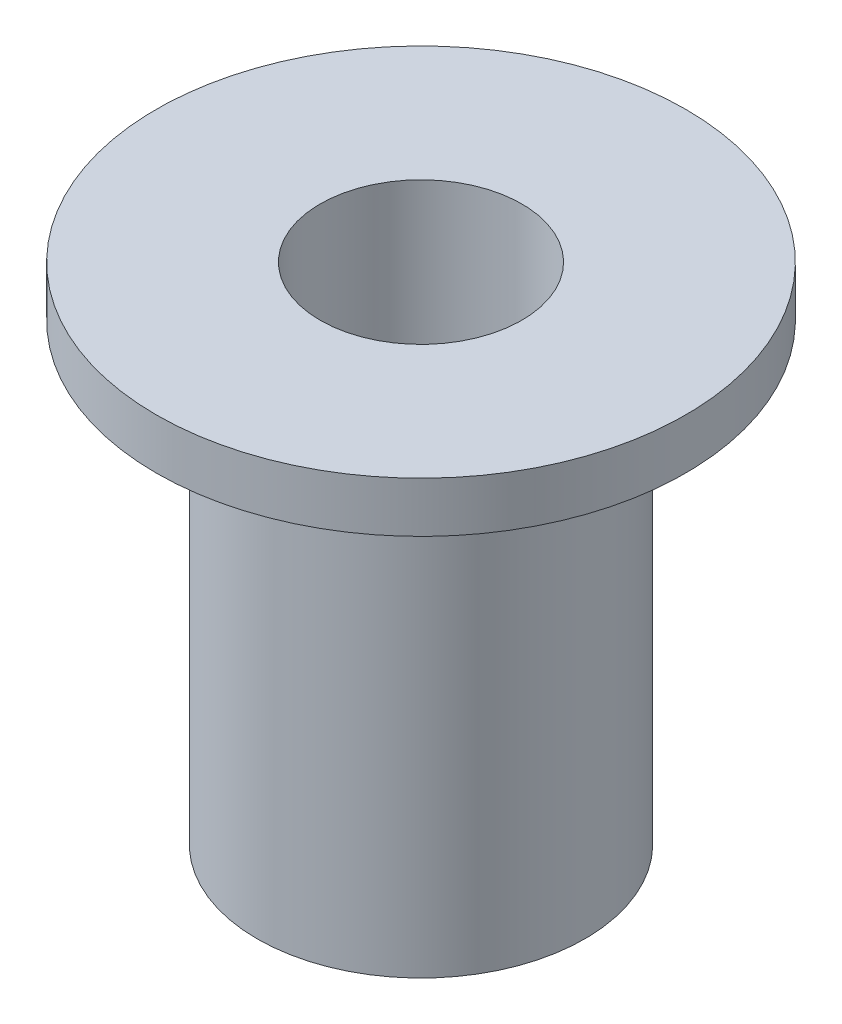
from build123d import *

# Parameters (mm, degrees)
SKETCH1_R           = 6.5
BOSS_EXTRUDE1_DEPTH = 20
SKETCH2_R           = 4
CUT_EXTRUDE1_DEPTH  = 16
SKETCH3_R           = 2
CUT_EXTRUDE2_DEPTH  = 5
SKETCH4_R           = 10.5
SKETCH4_R_2         = 6.5
BOSS_EXTRUDE2_DEPTH = 2


with BuildPart() as part:
    # Sketch1 → Boss-Extrude1 (new body)
    with BuildSketch(Plane(origin=(0, 0, 0), x_dir=(1, 0, 0), z_dir=(0, 1, 0))):
        Circle(SKETCH1_R)
    extrude(amount=BOSS_EXTRUDE1_DEPTH)

    # Sketch2 → Cut-Extrude1 (cut)
    with BuildSketch(Plane(origin=(0, 20, 0), x_dir=(1, 0, 0), z_dir=(0, 1, 0))):
        Circle(SKETCH2_R)
    extrude(amount=-CUT_EXTRUDE1_DEPTH, mode=Mode.SUBTRACT)

    # Sketch3 → Cut-Extrude2 (cut, through all)
    with BuildSketch(Plane(origin=(0, 4, 0), x_dir=(1, 0, 0), z_dir=(0, 1, 0))):
        Circle(SKETCH3_R)
    extrude(amount=-CUT_EXTRUDE2_DEPTH, mode=Mode.SUBTRACT)

    # Sketch4 → Boss-Extrude2 (add)
    with BuildSketch(Plane(origin=(0, 20, 0), x_dir=(1, 0, 0), z_dir=(0, 1, 0))):
        Circle(SKETCH4_R)
        Circle(SKETCH4_R_2, mode=Mode.SUBTRACT)
    extrude(amount=-BOSS_EXTRUDE2_DEPTH)


solid = part.part
